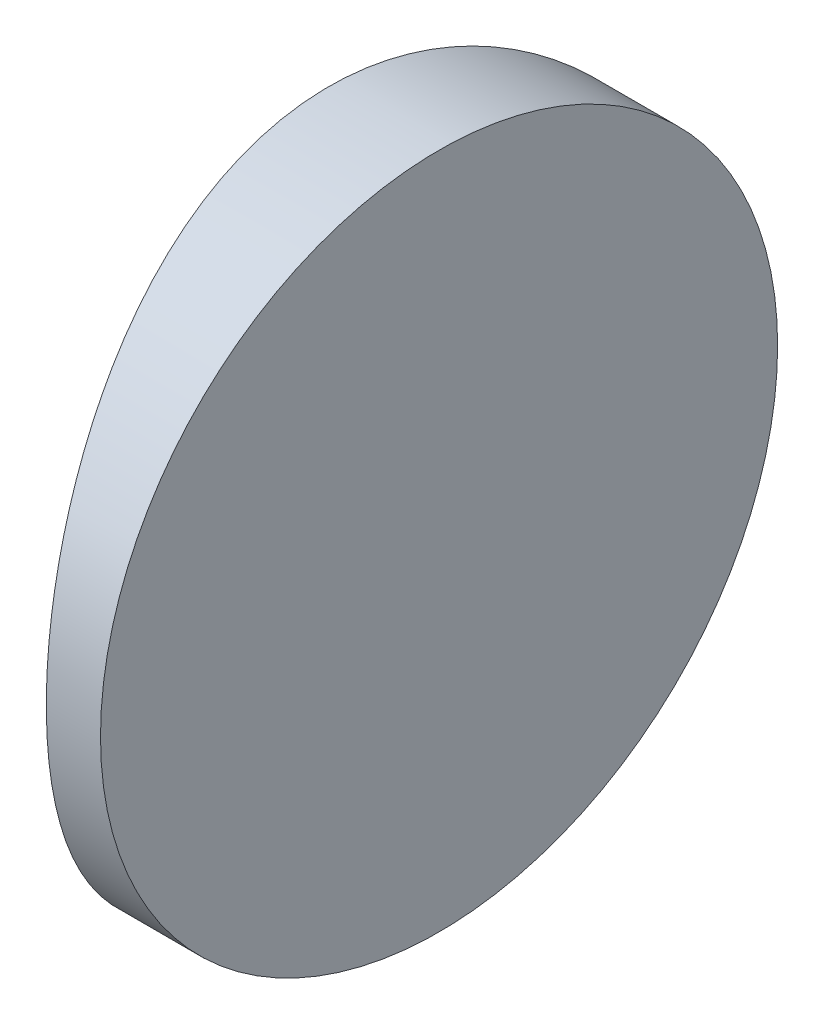
from build123d import *

# Parameters (mm, degrees)
EXTRUDE_1_DEPTH     = 25
CUT_EXTRUDE_8_DEPTH = 12.7


with BuildPart() as part:
    # 草图1 → 凸台-拉伸1 (new body)
    with BuildSketch(Plane(origin=(0, 0, 0), x_dir=(1, 0, 0), z_dir=(0, 1, 0))):
        with BuildLine():
            Line((-32.354990434, 12.5), (-30.354795665, 12.5))
            Line((-30.354795665, 12.5), (-30.354795665, -12.5))
            Line((-30.354795665, -12.5), (-32.354990434, -12.5))
            ThreePointArc((-32.354990434, -12.5), (-34.424795665, 0), (-32.354990434, 12.5))
        make_face()
    extrude(amount=EXTRUDE_1_DEPTH)

    # 草图2 → 切除-拉伸8 (cut)
    with BuildSketch(Plane(origin=(-30.354795665, 0, 0), x_dir=(0, 0, -1), z_dir=(1, 0, 0))):
        with BuildLine():
            Line((-12.5, 25), (-12.5, 12.5))
            ThreePointArc((-12.5, 12.5), (-8.838834765, 21.338834765), (0, 25))
            Line((0, 25), (-12.5, 25))
        make_face()
        with BuildLine():
            ThreePointArc((0, 25), (8.838834765, 21.338834765), (12.5, 12.5))
            Line((12.5, 12.5), (12.5, 25))
            Line((12.5, 25), (0, 25))
        make_face()
        with BuildLine():
            ThreePointArc((12.5, 12.5), (8.838834765, 3.661165235), (0, 0))
            Line((0, 0), (12.5, 0))
            Line((12.5, 0), (12.5, 12.5))
        make_face()
        with BuildLine():
            Line((-12.5, 12.5), (-12.5, 0))
            Line((-12.5, 0), (0, 0))
            ThreePointArc((0, 0), (-8.838834765, 3.661165235), (-12.5, 12.5))
        make_face()
    extrude(amount=-CUT_EXTRUDE_8_DEPTH, mode=Mode.SUBTRACT)


solid = part.part
